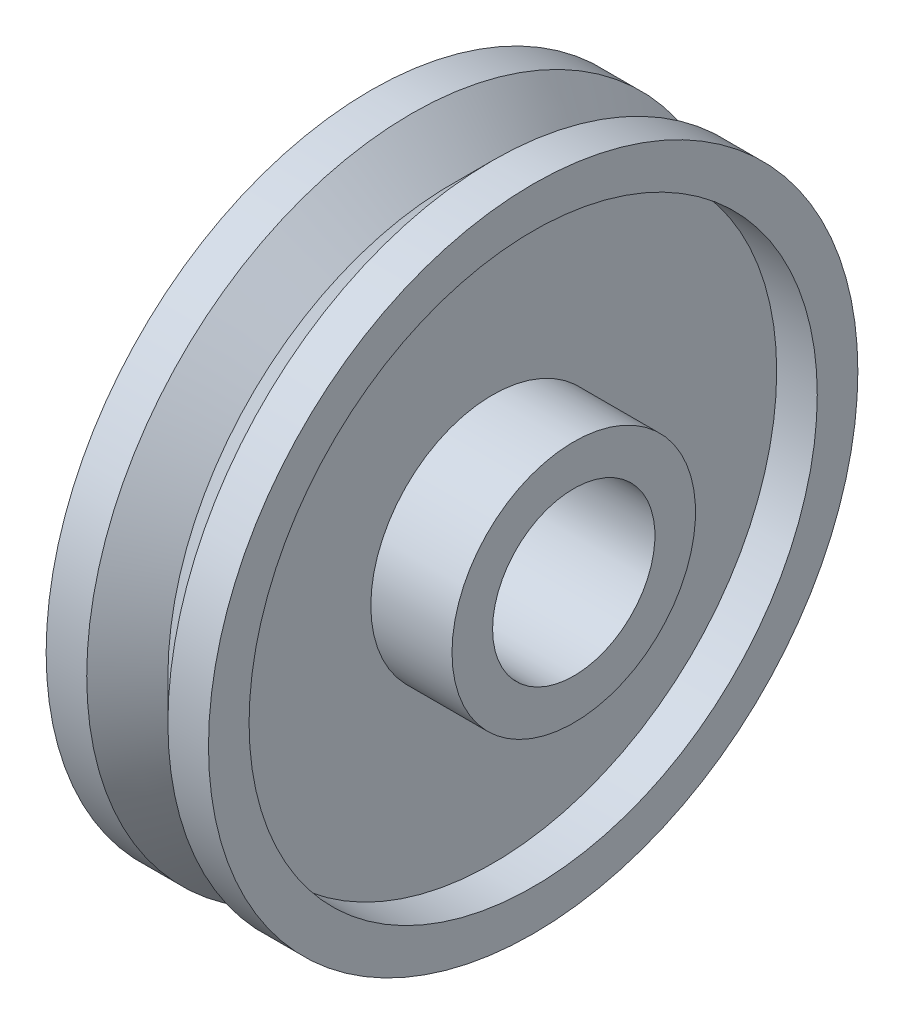
from build123d import *


with BuildPart() as part:
    # Sketch1 → Revolve1 (revolve)
    with BuildSketch(Plane.XY):
        Polygon((-19.05, 12.7), (19.05, 12.7), (19.05, 19.05), (6.35, 19.05), (6.35, 44.45), (12.7, 44.45), (12.7, 50.8), (6.35, 50.8), (0, 44.45), (-6.35, 50.8), (-12.7, 50.8), (-12.7, 44.45), (-6.35, 44.45), (-6.35, 19.05), (-19.05, 19.05), align=None)
    revolve(axis=Axis((-487.032527769, 0, 0), (1, 0, 0)))


solid = part.part
